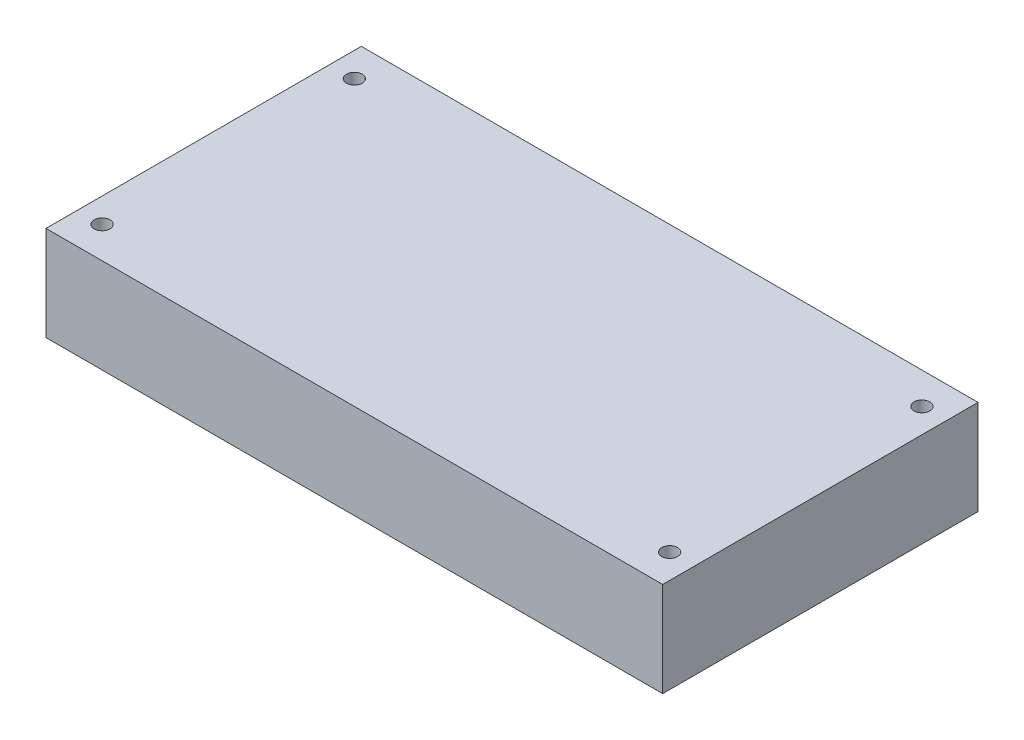
from build123d import *

# Parameters (mm, degrees)
SKETCH1_W           = 97.79
SKETCH1_H           = 50
SKETCH1_R           = 1.25
BOSS_EXTRUDE1_DEPTH = 15


with BuildPart() as part:
    # Sketch1 → Boss-Extrude1 (new body)
    with BuildSketch(Plane(origin=(0, 0, 0), x_dir=(1, 0, 0), z_dir=(0, 1, 0))):
        Rectangle(SKETCH1_W, SKETCH1_H)
        with Locations((45, 20)):
            Circle(SKETCH1_R, mode=Mode.SUBTRACT)
        with Locations((-45, 20)):
            Circle(SKETCH1_R, mode=Mode.SUBTRACT)
        with Locations((45, -20)):
            Circle(SKETCH1_R, mode=Mode.SUBTRACT)
        with Locations((-45, -20)):
            Circle(SKETCH1_R, mode=Mode.SUBTRACT)
    extrude(amount=BOSS_EXTRUDE1_DEPTH)


solid = part.part
